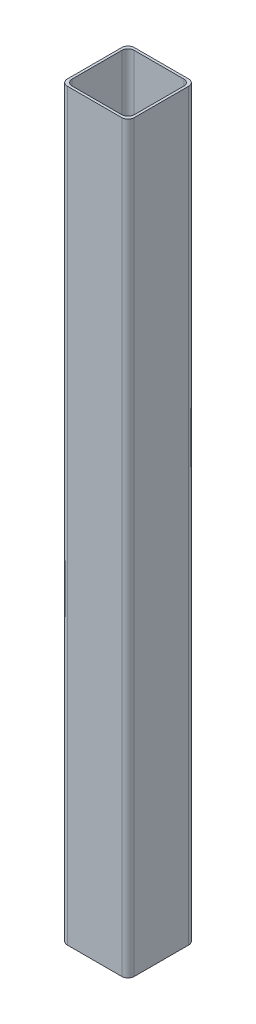
from build123d import *

# Parameters (mm, degrees)
BOSS_EXTRUDE1_DEPTH = 304.8


with BuildPart() as part:
    # Sketch1 → Boss-Extrude1 (new body)
    with BuildSketch(Plane(origin=(0, 0, 0), x_dir=(1, 0, 0), z_dir=(0, 1, 0))):
        with BuildLine():
            Line((-11.176, -13.716), (11.176, -13.716))
            ThreePointArc((11.176, -13.716), (12.972051224, -12.972051224), (13.716, -11.176))
            Line((13.716, -11.176), (13.716, 11.176))
            ThreePointArc((13.716, 11.176), (12.972051224, 12.972051224), (11.176, 13.716))
            Line((11.176, 13.716), (-11.176, 13.716))
            ThreePointArc((-11.176, 13.716), (-12.972051224, 12.972051224), (-13.716, 11.176))
            Line((-13.716, 11.176), (-13.716, -11.176))
            ThreePointArc((-13.716, -11.176), (-12.972051224, -12.972051224), (-11.176, -13.716))
        make_face()
        with BuildLine():
            Line((-10.16, -12.7), (10.16, -12.7))
            ThreePointArc((10.16, -12.7), (11.956051224, -11.956051224), (12.7, -10.16))
            Line((12.7, -10.16), (12.7, 10.16))
            ThreePointArc((12.7, 10.16), (11.956051224, 11.956051224), (10.16, 12.7))
            Line((10.16, 12.7), (-10.16, 12.7))
            ThreePointArc((-10.16, 12.7), (-11.956051224, 11.956051224), (-12.7, 10.16))
            Line((-12.7, 10.16), (-12.7, -10.16))
            ThreePointArc((-12.7, -10.16), (-11.956051224, -11.956051224), (-10.16, -12.7))
        make_face(mode=Mode.SUBTRACT)
    extrude(amount=BOSS_EXTRUDE1_DEPTH)


solid = part.part
